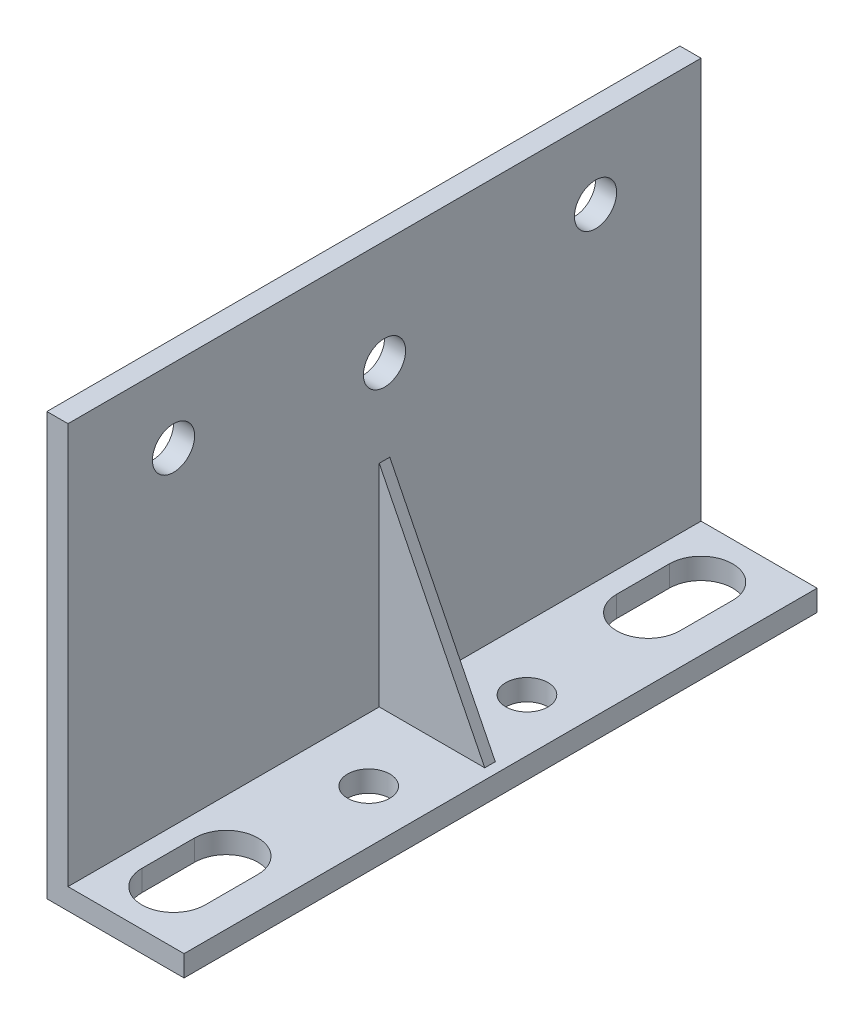
from build123d import *

# Parameters (mm, degrees)
BOSS_EXTRUDE1_DEPTH = 60
BOSS_EXTRUDE2_DEPTH = 0.5
CUT_EXTRUDE1_DEPTH  = 2
CUT_EXTRUDE2_REACH  = 15
SKETCH6_R           = 2
CUT_EXTRUDE3_REACH  = 4
SKETCH7_R           = 2
SKETCH8_R           = 2
CUT_EXTRUDE4_DEPTH  = 2


with BuildPart() as part:
    # Sketch1 → Boss-Extrude1 (new body)
    with BuildSketch(Plane.XY):
        Polygon((0, 0), (-11, 0), (-11, 38), (-13, 38), (-13, -2), (0, -2), align=None)
    extrude(amount=BOSS_EXTRUDE1_DEPTH)

    # Sketch4 → Boss-Extrude2 (add, symmetric)
    with BuildSketch(Plane.XY.offset(30)):
        Polygon((-11, 20), (-1, 0), (-11, 0), align=None)
    extrude(amount=BOSS_EXTRUDE2_DEPTH, both=True)

    # Sketch5 → Cut-Extrude1 (cut)
    with BuildSketch(Plane(origin=(0, 0, 0), x_dir=(1, 0, 0), z_dir=(0, 1, 0))):
        with BuildLine():
            Line((-3, -5), (-3, -10))
            ThreePointArc((-3, -10), (-6, -13), (-9, -10))
            Line((-9, -10), (-9, -5))
            ThreePointArc((-9, -5), (-6, -2), (-3, -5))
        make_face()
    cut_extrude1 = extrude(amount=-CUT_EXTRUDE1_DEPTH, mode=Mode.SUBTRACT)

    # Mirror1: Cut-Extrude1 across plane
    add(cut_extrude1.mirror(Plane.XY.offset(30)), mode=Mode.SUBTRACT)

    # Sketch6 → Cut-Extrude2 (cut, up to next)
    with BuildSketch(Plane(origin=(-13, 0, 0), x_dir=(0, 0, -1), z_dir=(1, 0, 0)), mode=Mode.PRIVATE) as cut_extrude2_sk1:
        with Locations((-50, 31)):
            Circle(SKETCH6_R)
    cut_extrude2_tool1 = extrude(cut_extrude2_sk1.sketch, amount=CUT_EXTRUDE2_REACH, mode=Mode.PRIVATE) & part.part
    add(cut_extrude2_tool1.solids().sort_by_distance((-13, 31, 50))[0], mode=Mode.SUBTRACT)
    # Sketch6 → Cut-Extrude2 (cut, up to next)
    with BuildSketch(Plane(origin=(-13, 0, 0), x_dir=(0, 0, -1), z_dir=(1, 0, 0)), mode=Mode.PRIVATE) as cut_extrude2_sk2:
        with Locations((-10, 31)):
            Circle(SKETCH6_R)
    cut_extrude2_tool2 = extrude(cut_extrude2_sk2.sketch, amount=CUT_EXTRUDE2_REACH, mode=Mode.PRIVATE) & part.part
    add(cut_extrude2_tool2.solids().sort_by_distance((-13, 31, 10))[0], mode=Mode.SUBTRACT)

    # Sketch7 → Cut-Extrude3 (cut, up to next)
    with BuildSketch(Plane(origin=(-11, 0, 0), x_dir=(0, 0, -1), z_dir=(1, 0, 0)), mode=Mode.PRIVATE) as cut_extrude3_sk1:
        with Locations((-30, 28)):
            Circle(SKETCH7_R)
    cut_extrude3_tool1 = extrude(cut_extrude3_sk1.sketch, amount=-CUT_EXTRUDE3_REACH, mode=Mode.PRIVATE) & part.part
    add(cut_extrude3_tool1.solids().sort_by_distance((-11, 28, 30))[0], mode=Mode.SUBTRACT)

    # Sketch8 → Cut-Extrude4 (cut)
    with BuildSketch(Plane(origin=(0, 0, 0), x_dir=(1, 0, 0), z_dir=(0, 1, 0))):
        with Locations((-5, -37.5)):
            Circle(SKETCH8_R)
    cut_extrude4 = extrude(amount=-CUT_EXTRUDE4_DEPTH, mode=Mode.SUBTRACT)

    # Mirror2: Cut-Extrude4 across plane
    add(cut_extrude4.mirror(Plane.XY.offset(30)), mode=Mode.SUBTRACT)


solid = part.part
